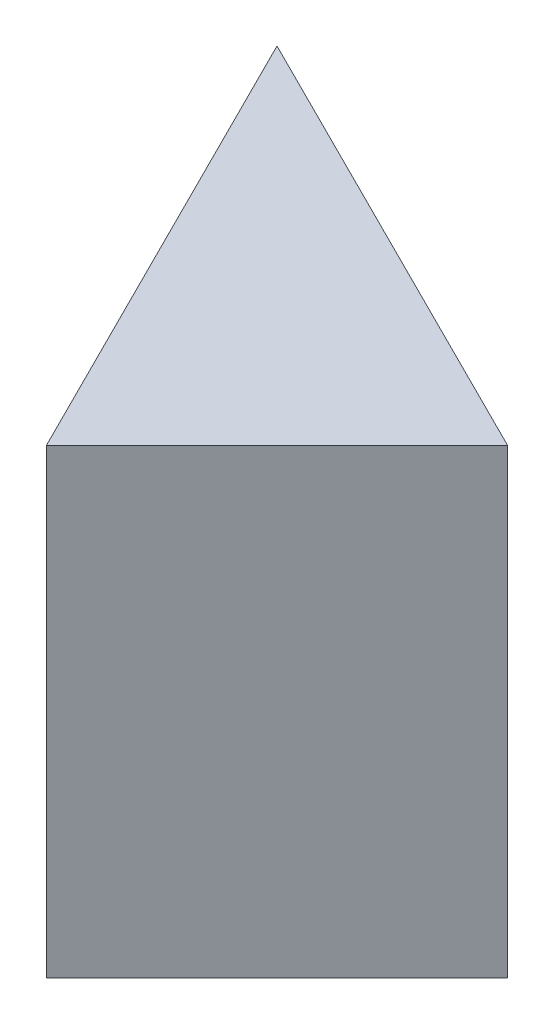
from build123d import *

# Parameters (mm, degrees)
SKETCH1_W           = 20
SKETCH1_H           = 20
BOSS_EXTRUDE1_DEPTH = 20
CUT_EXTRUDE1_DEPTH  = 20
CUT_EXTRUDE2_DEPTH  = 20
CUT_EXTRUDE3_DEPTH  = 20


with BuildPart() as part:
    # Sketch1 → Boss-Extrude1 (new body)
    with BuildSketch(Plane.XY):
        with Locations((10, 10)):
            Rectangle(SKETCH1_W, SKETCH1_H)
    extrude(amount=BOSS_EXTRUDE1_DEPTH)

    # Sketch2 → Cut-Extrude1 (cut)
    with BuildSketch(Plane(origin=(0, 20, 0), x_dir=(1, 0, 0), z_dir=(0, 1, 0))):
        Polygon((0, 0), (20, 0), (20, -10), align=None)
    extrude(amount=-CUT_EXTRUDE1_DEPTH, mode=Mode.SUBTRACT)

    # Sketch3 → Cut-Extrude2 (cut)
    with BuildSketch(Plane(origin=(0, 20, 0), x_dir=(1, 0, 0), z_dir=(0, 1, 0))):
        Polygon((0, 0), (0, -20), (10, -20), align=None)
    extrude(amount=-CUT_EXTRUDE2_DEPTH, mode=Mode.SUBTRACT)

    # Sketch4 → Cut-Extrude3 (cut)
    with BuildSketch(Plane(origin=(0, 20, 0), x_dir=(1, 0, 0), z_dir=(0, 1, 0))):
        Polygon((20, -20), (20, -10), (10, -20), align=None)
    extrude(amount=-CUT_EXTRUDE3_DEPTH, mode=Mode.SUBTRACT)


solid = part.part
